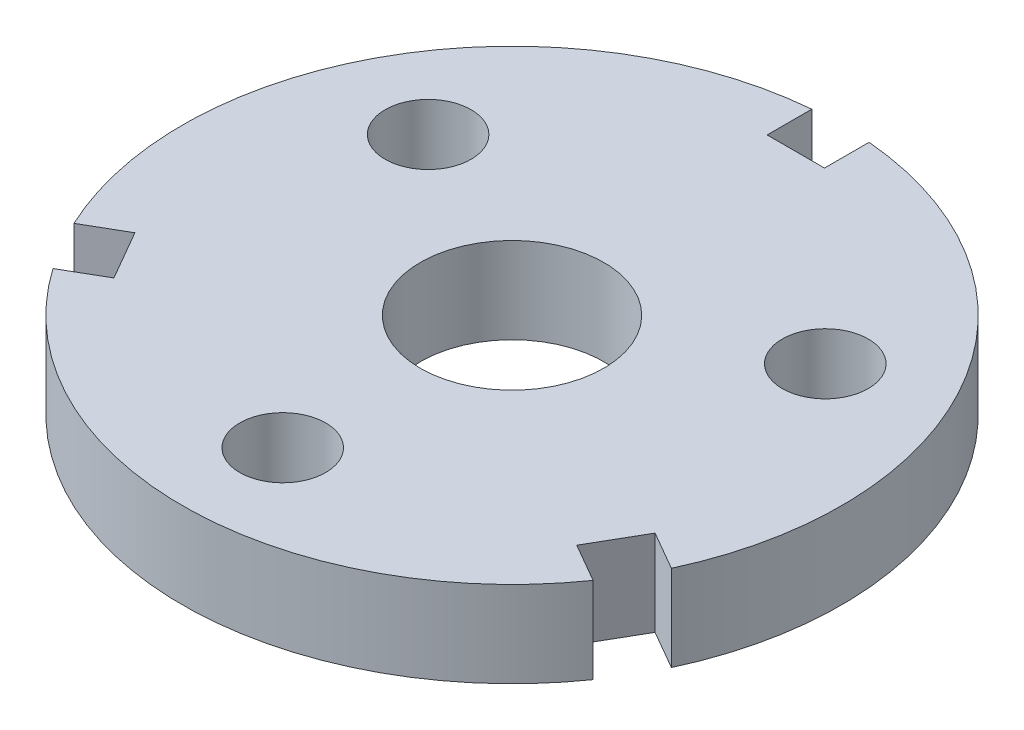
from build123d import *

# Parameters (mm, degrees)
SKETCH1_R           = 16
SKETCH1_R_2         = 7.5
BOSS_EXTRUDE1_DEPTH = 15


with BuildPart() as part:
    # Sketch1 → Boss-Extrude1 (new body)
    with BuildSketch(Plane(origin=(0, 0, 0), x_dir=(1, 0, 0), z_dir=(0, 1, 0))):
        with BuildLine():
            Line((-5, 57.282196187), (-5, 49.5))
            Line((-5, 49.5), (5, 49.5))
            Line((5, 49.5), (5, 57.282196187))
            ThreePointArc((5, 57.282196187), (49.796460718, 28.75), (52.107837082, -24.310971075))
            Line((52.107837082, -24.310971075), (45.368257487, -20.419872981))
            Line((45.368257487, -20.419872981), (40.368257487, -29.080127019))
            Line((40.368257487, -29.080127019), (47.107837082, -32.971225112))
            ThreePointArc((47.107837082, -32.971225112), (0, -57.5), (-47.107837082, -32.971225112))
            Line((-47.107837082, -32.971225112), (-40.368257487, -29.080127019))
            Line((-40.368257487, -29.080127019), (-45.368257487, -20.419872981))
            Line((-45.368257487, -20.419872981), (-52.107837082, -24.310971075))
            ThreePointArc((-52.107837082, -24.310971075), (-49.796460718, 28.75), (-5, 57.282196187))
        make_face()
        Circle(SKETCH1_R, mode=Mode.SUBTRACT)
        with Locations((34.641016151, 20)):
            Circle(SKETCH1_R_2, mode=Mode.SUBTRACT)
        with Locations((0, -40)):
            Circle(SKETCH1_R_2, mode=Mode.SUBTRACT)
        with Locations((-34.641016151, 20)):
            Circle(SKETCH1_R_2, mode=Mode.SUBTRACT)
    extrude(amount=BOSS_EXTRUDE1_DEPTH)


solid = part.part
